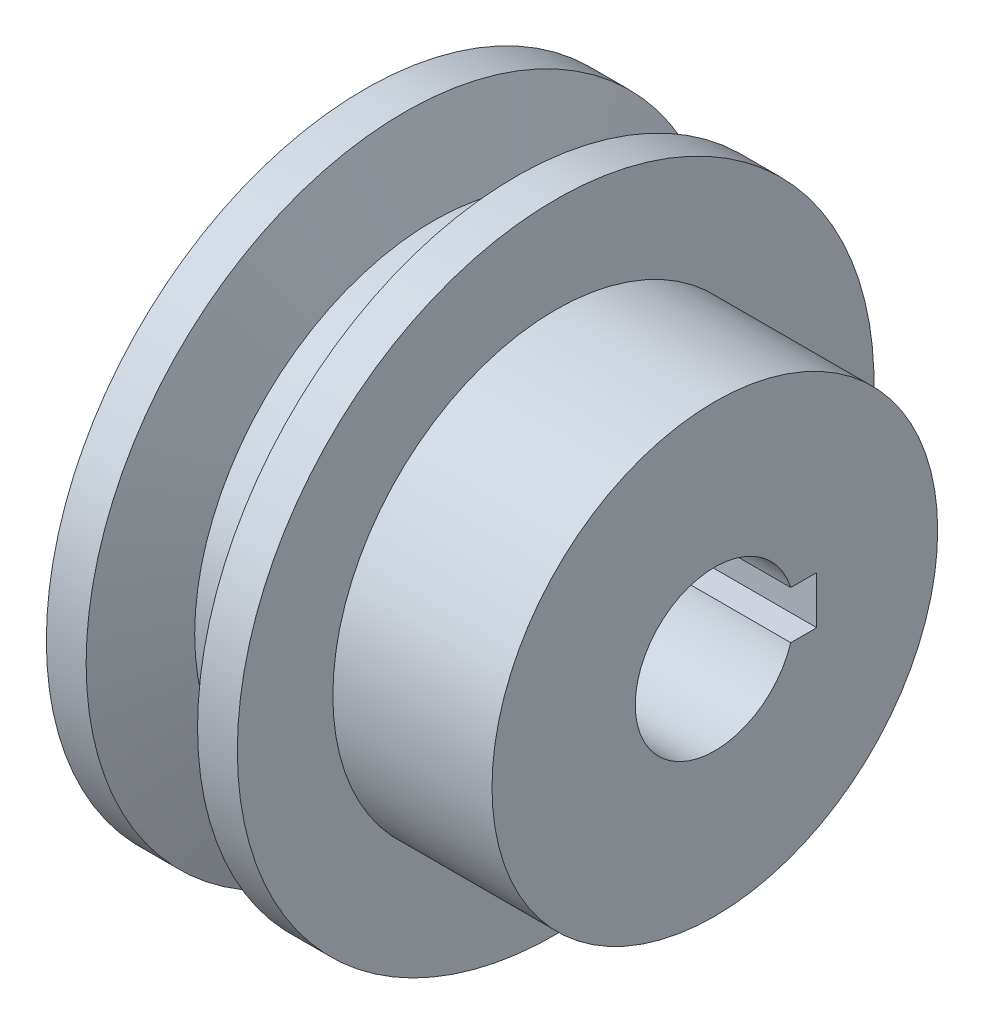
from build123d import *

# Parameters (mm, degrees)
CUT_EXTRUDE1_DEPTH      = 1
CUT_EXTRUDE1_DEPTH_BACK = 23


with BuildPart() as part:
    # Sketch1 → Revolve1 (revolve)
    with BuildSketch(Plane.XY):
        Polygon((-6.562817936, 5), (-6.562817936, 20), (-4.062817936, 20), (-2.242966765, 15), (1.117330893, 15), (2.937182064, 20), (5.437182064, 20), (5.437182064, 14), (15.437182064, 14), (15.437182064, 5), align=None)
    revolve(axis=Axis((-16.510808735, 0, 0), (1, 0, 0)))

    # Sketch2 → Cut-Extrude1 (cut, two sides)
    with BuildSketch(Plane(origin=(15.437182064, 0, 0), x_dir=(0, 0, -1), z_dir=(1, 0, 0))) as cut_extrude1_sk:
        with BuildLine():
            Line((4.769696007, -1.5), (6.4, -1.5))
            Line((6.4, -1.5), (6.4, 1.5))
            Line((6.4, 1.5), (4.769696007, 1.5))
            ThreePointArc((4.769696007, 1.5), (5, 0), (4.769696007, -1.5))
        make_face()
    extrude(amount=CUT_EXTRUDE1_DEPTH, mode=Mode.SUBTRACT)
    extrude(cut_extrude1_sk.sketch, amount=-CUT_EXTRUDE1_DEPTH_BACK, mode=Mode.SUBTRACT)


solid = part.part
